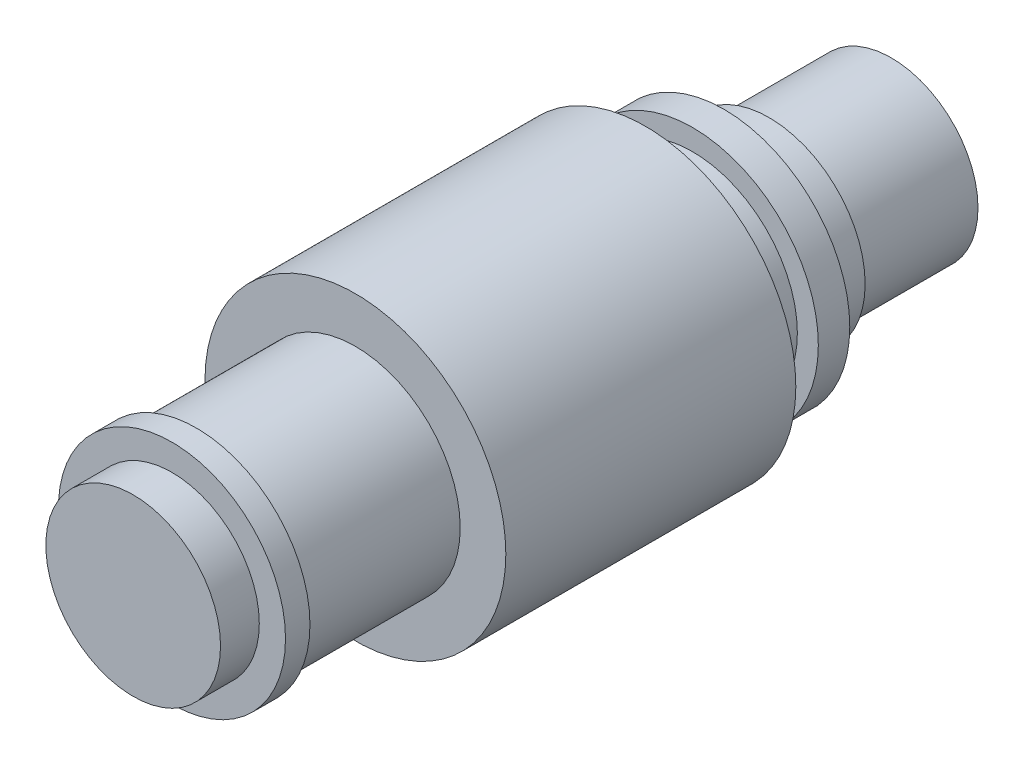
from build123d import *

# Parameters (mm, degrees)
SKETCH4_R           = 43.057541212
BOSS_EXTRUDE1_DEPTH = 41.5


with BuildPart() as part:
    # Sketch3 → Revolve1 (revolve)
    with BuildSketch(Plane(origin=(0, 0, 0), x_dir=(0, 0, -1), z_dir=(1, 0, 0))):
        Polygon((0, 0), (217, 0), (217, 24.8), (182, 24.8), (182, 27.500000118), (169.1, 27.500000118), (169.1, 36), (160.1, 36), (160.1, 30), (18.1, 30), (18.1, 32.5), (11.1, 32.5), (11.1, 25), (0, 25), align=None)
    revolve(axis=Axis((0, 0, 0), (0, 0, -1)))

    # Sketch4 → Boss-Extrude1 (add, symmetric)
    with BuildSketch(Plane.XY.offset(-105.1)):
        Circle(SKETCH4_R)
    extrude(amount=BOSS_EXTRUDE1_DEPTH, both=True)


solid = part.part
